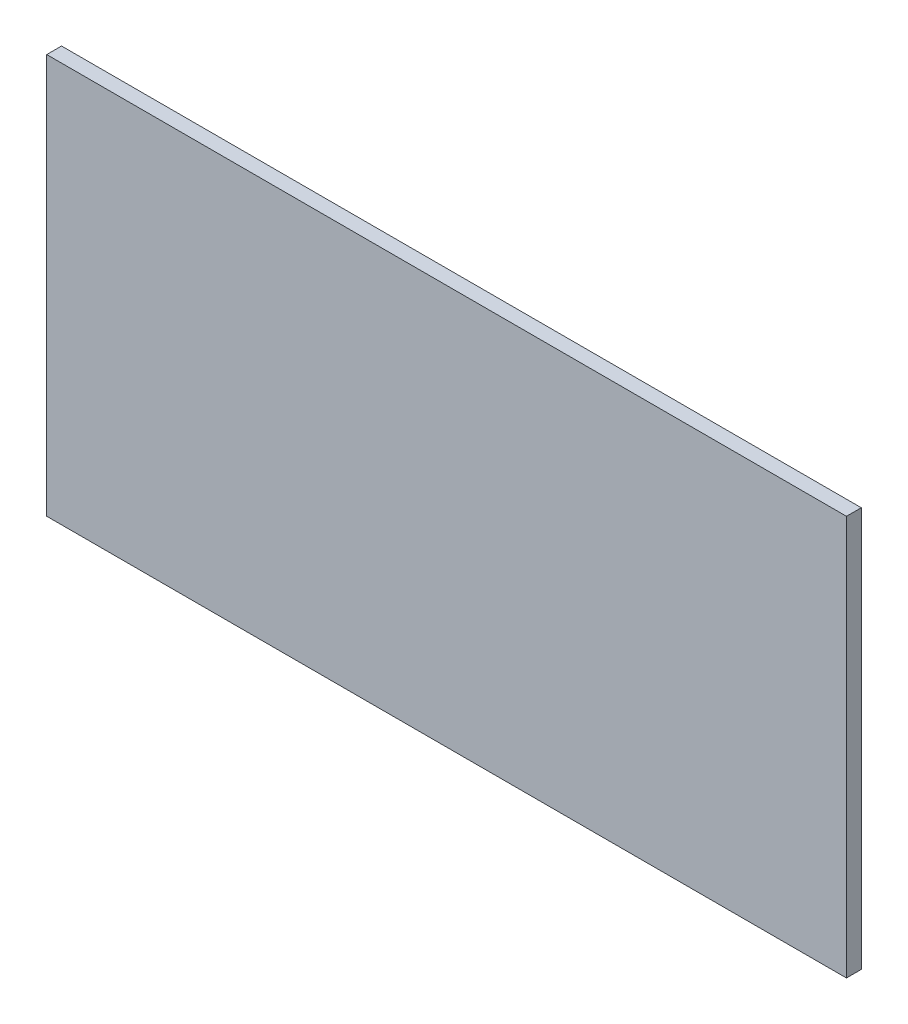
from build123d import *

# Parameters (mm, degrees)
SKETCH1_W           = 540
SKETCH1_H           = 270
BOSS_EXTRUDE1_DEPTH = 10


with BuildPart() as part:
    # Sketch1 → Boss-Extrude1 (new body)
    with BuildSketch(Plane.XY):
        Rectangle(SKETCH1_W, SKETCH1_H)
    extrude(amount=BOSS_EXTRUDE1_DEPTH)


solid = part.part
